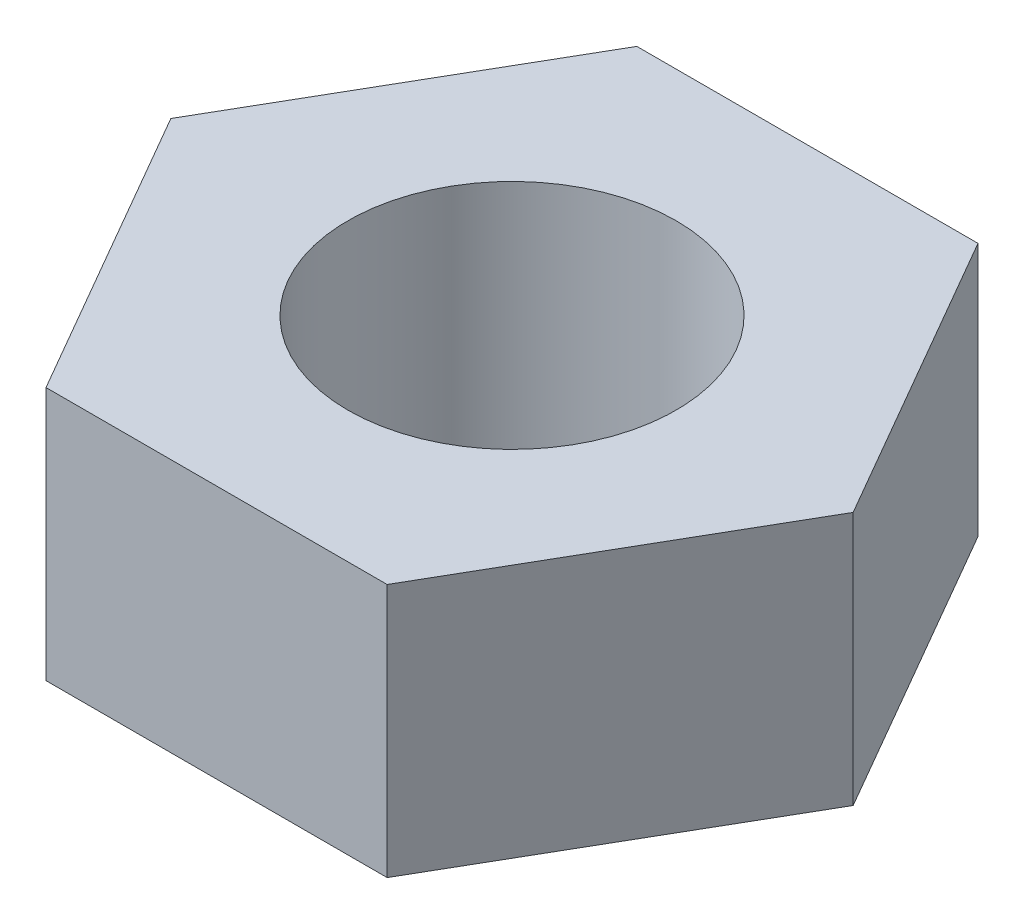
from build123d import *

# Parameters (mm, degrees)
SKETCH1_R           = 1.5
BOSS_EXTRUDE1_DEPTH = 2.32


with BuildPart() as part:
    # Sketch1 → Boss-Extrude1 (new body)
    with BuildSketch(Plane(origin=(0, 0, 0), x_dir=(1, 0, 0), z_dir=(0, 1, 0))):
        Polygon((-1.558845727, 2.7), (-3.117691454, 0), (-1.558845727, -2.7), (1.558845727, -2.7), (3.117691454, 0), (1.558845727, 2.7), align=None)
        Circle(SKETCH1_R, mode=Mode.SUBTRACT)
    extrude(amount=BOSS_EXTRUDE1_DEPTH)


solid = part.part
